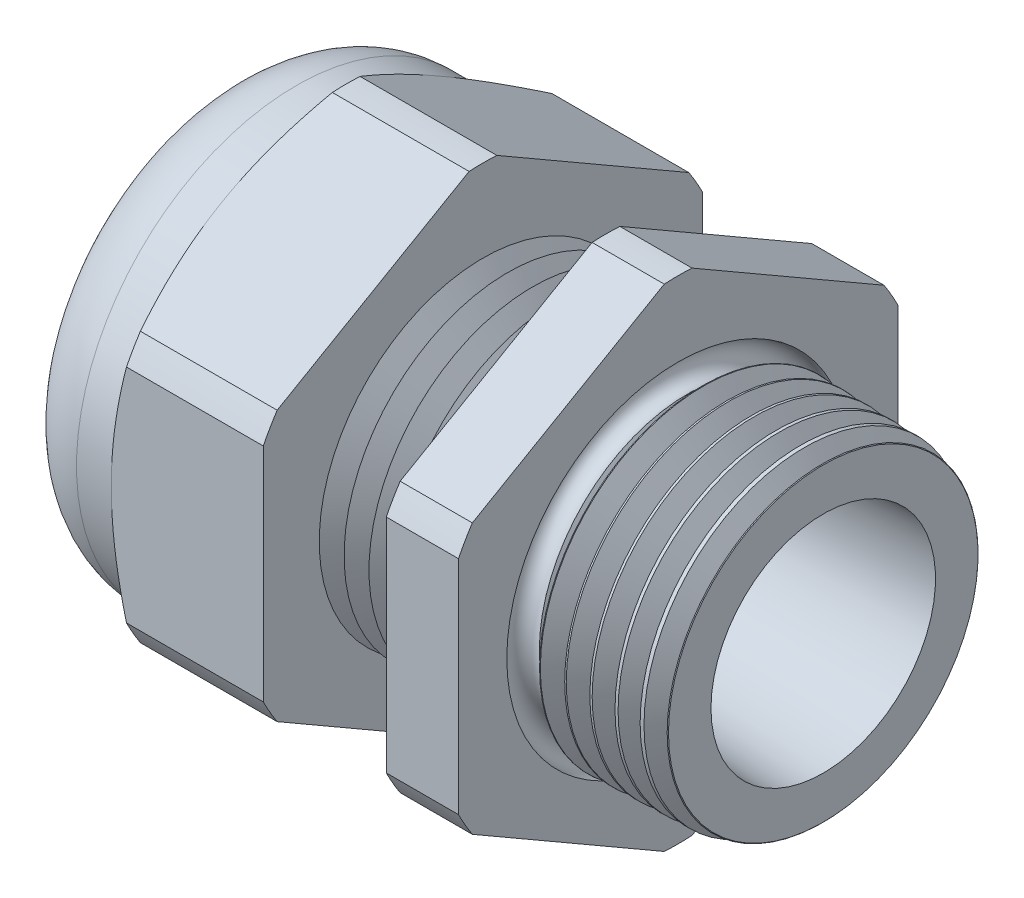
from build123d import *

# Parameters (mm, degrees)
SKETCH2_OUTSIDE_W  = 43.424
SKETCH2_OUTSIDE_H  = 43.424
CUT_EXTRUDE1_DEPTH = 21.2725
CHAMFER1_SIZE      = 0.326149358
CHAMFER1_SIZE2     = 0.3175
SKETCH3_OUTSIDE_W  = 147.812
SKETCH3_OUTSIDE_H  = 151.042
SKETCH3_OUTSIDE_R  = 13.462
CUT_EXTRUDE2_DEPTH = 31.1625
CUT_EXTRUDE2_DRAFT = -60
SKETCH14_W         = 6.6675
SKETCH14_H         = 3.429
FILLET1_R          = 4.53644
LPATTERN1_COUNT    = 5
LPATTERN1_PITCH    = 1.524
LPATTERN2_COUNT    = 6
LPATTERN2_PITCH    = 1.524
SKETCH15_R         = 0.8255


with BuildPart() as part:
    # Sketch1 → Revolve1 (revolve)
    with BuildSketch(Plane.XY, mode=Mode.PRIVATE) as revolve1_sk:
        Polygon((-11.959166667, 10.033), (-11.959166667, 15.07744), (-21.2725, 15.07744), (-21.2725, 10.033), (-27.94, 10.033), (-27.94, 8.52805), (-21.2725, 8.52805), (-21.2725, 5.969), (-11.959166667, 5.969), (8.89, 6.879294276), (8.89, 9.800207157), (0, 10.033), (0, 15.07744), (-4.422885572, 15.07744), (-4.422885572, 10.033), align=None)
    revolve(revolve1_sk.sketch.rotate(Axis((-18.386021217, 0, 0), (1, 0, 0)), 90), axis=Axis((-18.386021217, 0, 0), (1, 0, 0)))  # turned: the seam where the file's is

    # Sketch2 outside → Cut-Extrude1 (cut)
    with BuildSketch(Plane(origin=(0, 0, 0), x_dir=(0, 0, -1), z_dir=(1, 0, 0))):
        Rectangle(SKETCH2_OUTSIDE_W, SKETCH2_OUTSIDE_H)
        with BuildLine():
            Line((13.462, -6.789974444), (13.462, 6.789974444))
            ThreePointArc((13.462, 6.789974444), (13.057446064, 7.53872), (12.61129036, 8.263446764))
            Line((12.61129036, 8.263446764), (0.85070964, 15.053421208))
            ThreePointArc((0.85070964, 15.053421208), (0, 15.07744), (-0.85070964, 15.053421208))
            Line((-0.85070964, 15.053421208), (-12.61129036, 8.263446764))
            ThreePointArc((-12.61129036, 8.263446764), (-13.057446064, 7.53872), (-13.462, 6.789974444))
            Line((-13.462, 6.789974444), (-13.462, -6.789974444))
            ThreePointArc((-13.462, -6.789974444), (-13.057446064, -7.53872), (-12.61129036, -8.263446764))
            Line((-12.61129036, -8.263446764), (-0.85070964, -15.053421208))
            ThreePointArc((-0.85070964, -15.053421208), (0, -15.07744), (0.85070964, -15.053421208))
            Line((0.85070964, -15.053421208), (12.61129036, -8.263446764))
            ThreePointArc((12.61129036, -8.263446764), (13.057446064, -7.53872), (13.462, -6.789974444))
        make_face(mode=Mode.SUBTRACT)
    extrude(amount=-CUT_EXTRUDE1_DEPTH, mode=Mode.SUBTRACT)

    # Chamfer1
    chamfer1_edges = [part.edges().sort_by_distance(p)[0] for p in [
        (8.89, 0, -9.800207157),
    ]]
    chamfer1_side = [part.faces().sort_by_distance(p)[0] for p in [
        (4.445, 0, -9.916603579),
    ]]
    chamfer(chamfer1_edges, length=CHAMFER1_SIZE, length2=CHAMFER1_SIZE2, reference=chamfer1_side[0])


with BuildPart() as cut_extrude2_tool:
    # Sketch3 outside → Cut-Extrude2 (with draft: the straight prism first)
    with BuildSketch(Plane.ZY.offset(21.2725)):
        Rectangle(SKETCH3_OUTSIDE_W, SKETCH3_OUTSIDE_H)
        Circle(SKETCH3_OUTSIDE_R, mode=Mode.SUBTRACT)
    extrude(amount=-CUT_EXTRUDE2_DEPTH)
    # Cut-Extrude2: the draft: its side faces are tilted about the plane it starts from
    cut_extrude2_sides = [cut_extrude2_tool.faces().sort_by_distance(p)[0] for p in [
        (-5.69125, -75.521, 0),
        (-5.69125, 0, 73.906),
        (-5.69125, 75.521, 0),
        (-5.69125, 0, -73.906),
        (-5.69125, 0, -13.462),
    ]]
    draft(cut_extrude2_sides, Plane.ZY.offset(21.2725), CUT_EXTRUDE2_DRAFT)


with BuildPart() as part_1:
    add(part.part)

    # Cut-Extrude2: cut by cut_extrude2_tool
    add(cut_extrude2_tool.part, mode=Mode.SUBTRACT)

    # Sketch14 → Revolve4 (revolve)
    with BuildSketch(Plane.XY, mode=Mode.PRIVATE) as revolve4_sk:
        with Locations((-24.60625, 11.7475)):
            Rectangle(SKETCH14_W, SKETCH14_H)
    revolve(revolve4_sk.sketch.rotate(Axis((-18.386021217, 0, 0), (1, 0, 0)), 90), axis=Axis((-18.386021217, 0, 0), (1, 0, 0)))  # turned: the seam where the file's is

    # Fillet1
    fillet1_edges = [part_1.edges().sort_by_distance(p)[0] for p in [
        (-27.94, 0, -13.462),
    ]]
    fillet(fillet1_edges, radius=FILLET1_R)

    # Sketch10 → Cut-Revolve1 (revolve, cut)
    with BuildSketch(Plane.XY, mode=Mode.PRIVATE) as cut_revolve1_sk:
        Polygon((-11.959166667, 10.033), (-11.197167022, 8.7131779), (-10.435167377, 10.033), align=None)
    cut_revolve1 = revolve(cut_revolve1_sk.sketch.rotate(Axis((15.58962545, 0, 0), (-1, 0, 0)), 270), axis=Axis((15.58962545, 0, 0), (-1, 0, 0)), mode=Mode.SUBTRACT)  # turned: the seam where the file's is

    # LPattern1: Cut-Revolve1 ×5
    with Locations(*[(i * LPATTERN1_PITCH, 0, 0) for i in range(1, LPATTERN1_COUNT)]):
        add(cut_revolve1, mode=Mode.SUBTRACT)

    # Sketch13 → Cut-Revolve2 (revolve, cut)
    with BuildSketch(Plane.XY, mode=Mode.PRIVATE) as cut_revolve2_sk:
        Polygon((0, 10.033), (1.523999289, 10.033), (0.761999645, 8.7131779), align=None)
    cut_revolve2 = revolve(cut_revolve2_sk.sketch.rotate(Axis((-18.386021217, 0, 0), (1, 0, 0)), 270), axis=Axis((-18.386021217, 0, 0), (1, 0, 0)), mode=Mode.SUBTRACT)  # turned: the seam where the file's is

    # LPattern2: Cut-Revolve2 ×6
    with Locations(*[(i * LPATTERN2_PITCH, 0, 0) for i in range(1, LPATTERN2_COUNT)]):
        add(cut_revolve2, mode=Mode.SUBTRACT)

    # Sketch15 → Cut-Revolve3 (revolve, cut)
    with BuildSketch(Plane.XY, mode=Mode.PRIVATE) as cut_revolve3_sk:
        with Locations((0, -9.673698712)):
            Circle(SKETCH15_R)
    revolve(cut_revolve3_sk.sketch.rotate(Axis((1.524, 0, 0), (-1, 0, 0)), 90), axis=Axis((1.524, 0, 0), (-1, 0, 0)), mode=Mode.SUBTRACT)  # turned: the seam where the file's is


with BuildPart() as body_2:
    # Sketch16 → Revolve5 (revolve)
    with BuildSketch(Plane.XY, mode=Mode.PRIVATE) as revolve5_sk:
        with BuildLine():
            Line((-26.924, 8.52805), (-21.2725, 8.52805))
            Line((-21.2725, 8.52805), (-21.2725, 5.969))
            Line((-21.2725, 5.969), (-27.178, 5.969))
            Line((-27.178, 5.969), (-27.178, 8.27405))
            ThreePointArc((-27.178, 8.27405), (-27.103605122, 8.453655122), (-26.924, 8.52805))
        make_face()
    revolve(revolve5_sk.sketch.rotate(Axis((-18.386021217, 0, 0), (1, 0, 0)), 90), axis=Axis((-18.386021217, 0, 0), (1, 0, 0)))  # turned: the seam where the file's is


solid = Compound([part_1.part, body_2.part])
